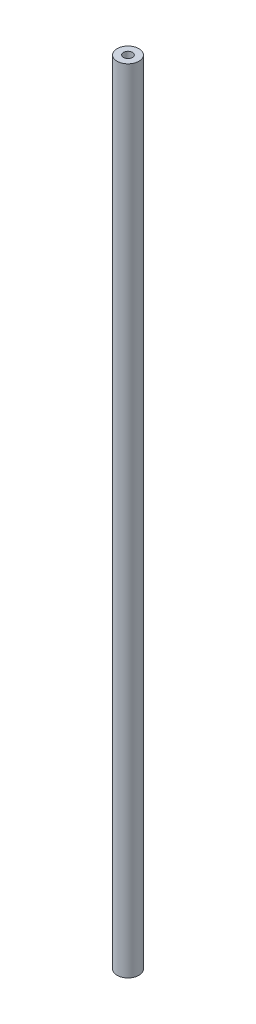
from build123d import *

# Parameters (mm, degrees)
SKETCH3_R             = 4
BOSS_EXTRUDE1_DEPTH   = 290
M4_TAPPED_HOLE1_D     = 3.3
M4_TAPPED_HOLE1_DEPTH = 2.4
M4_TAPPED_HOLE1_TIP   = 0.991420021
M4_TAPPED_HOLE2_D     = 3.3
M4_TAPPED_HOLE2_DEPTH = 2.4
M4_TAPPED_HOLE2_TIP   = 0.991420021


with BuildPart() as part:
    # Sketch3 → Boss-Extrude1 (new body)
    with BuildSketch(Plane(origin=(0, 0, 0), x_dir=(1, 0, 0), z_dir=(0, 1, 0))):
        Circle(SKETCH3_R)
    extrude(amount=BOSS_EXTRUDE1_DEPTH)

    # M4 Tapped Hole1
    with Locations(Plane(origin=(0, 290, 0), x_dir=(1, 0, 0), z_dir=(0, 1, 0))):
        with Locations((0, 0)):
            Hole(M4_TAPPED_HOLE1_D / 2, depth=M4_TAPPED_HOLE1_DEPTH)
            with Locations((0, 0, -(M4_TAPPED_HOLE1_DEPTH + M4_TAPPED_HOLE1_TIP / 2))):  # 118° drill point
                Cone(0, M4_TAPPED_HOLE1_D / 2, M4_TAPPED_HOLE1_TIP, mode=Mode.SUBTRACT)

    # M4 Tapped Hole2
    with Locations(Plane(origin=(0, 0, 0), x_dir=(-1, 0, 0), z_dir=(0, -1, 0))):
        with Locations((0, 0)):
            Hole(M4_TAPPED_HOLE2_D / 2, depth=M4_TAPPED_HOLE2_DEPTH)
            with Locations((0, 0, -(M4_TAPPED_HOLE2_DEPTH + M4_TAPPED_HOLE2_TIP / 2))):  # 118° drill point
                Cone(0, M4_TAPPED_HOLE2_D / 2, M4_TAPPED_HOLE2_TIP, mode=Mode.SUBTRACT)


solid = part.part
